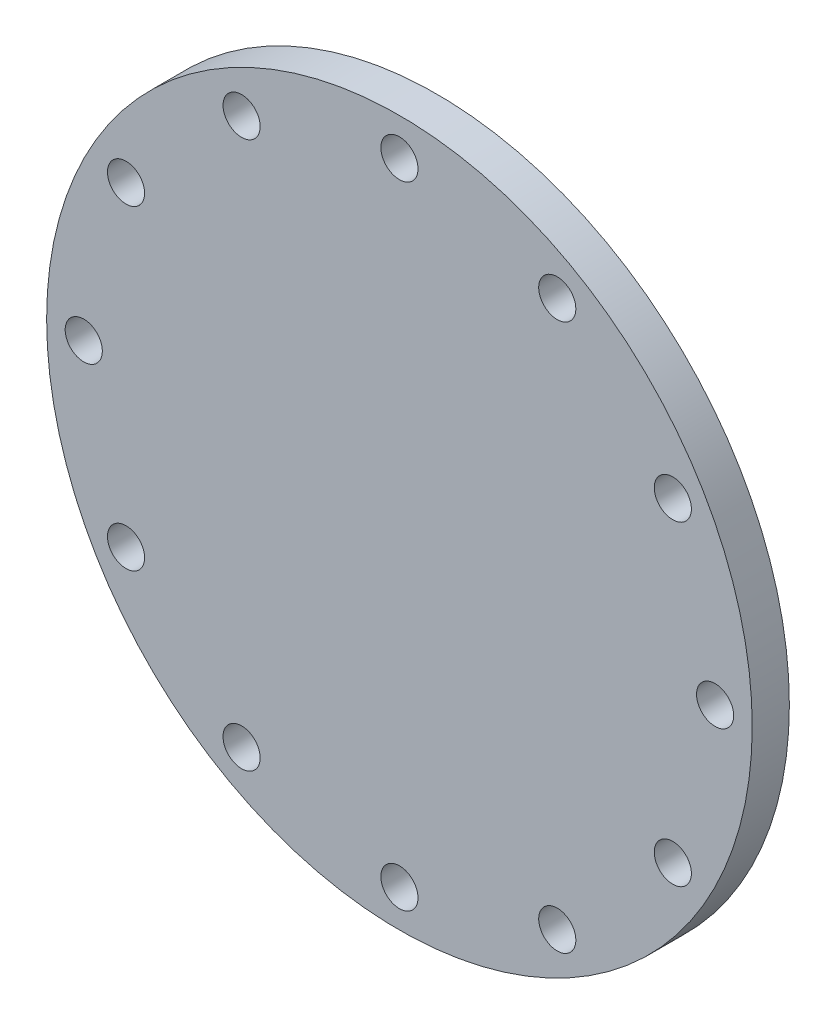
from build123d import *

# Parameters (mm, degrees)
SKETCH_R        = 241.3
SKETCH_R_2      = 12.7
EXTRUDE_2_DEPTH = 25.4


with BuildPart() as part:
    # Sketch → Extrude 2 (new body)
    with BuildSketch(Plane.XY):
        Circle(SKETCH_R)
        with Locations((0, 215.9)):
            Circle(SKETCH_R_2, mode=Mode.SUBTRACT)
        with Locations((107.95, 186.974884677)):
            Circle(SKETCH_R_2, mode=Mode.SUBTRACT)
        with Locations((186.974884677, 107.95)):
            Circle(SKETCH_R_2, mode=Mode.SUBTRACT)
        with Locations((215.9, 0)):
            Circle(SKETCH_R_2, mode=Mode.SUBTRACT)
        with Locations((186.974884677, -107.95)):
            Circle(SKETCH_R_2, mode=Mode.SUBTRACT)
        with Locations((107.95, -186.974884677)):
            Circle(SKETCH_R_2, mode=Mode.SUBTRACT)
        with Locations((0, -215.9)):
            Circle(SKETCH_R_2, mode=Mode.SUBTRACT)
        with Locations((-107.95, -186.974884677)):
            Circle(SKETCH_R_2, mode=Mode.SUBTRACT)
        with Locations((-186.974884677, -107.95)):
            Circle(SKETCH_R_2, mode=Mode.SUBTRACT)
        with Locations((-215.9, 0)):
            Circle(SKETCH_R_2, mode=Mode.SUBTRACT)
        with Locations((-186.974884677, 107.95)):
            Circle(SKETCH_R_2, mode=Mode.SUBTRACT)
        with Locations((-107.95, 186.974884677)):
            Circle(SKETCH_R_2, mode=Mode.SUBTRACT)
    extrude(amount=EXTRUDE_2_DEPTH)


solid = part.part
